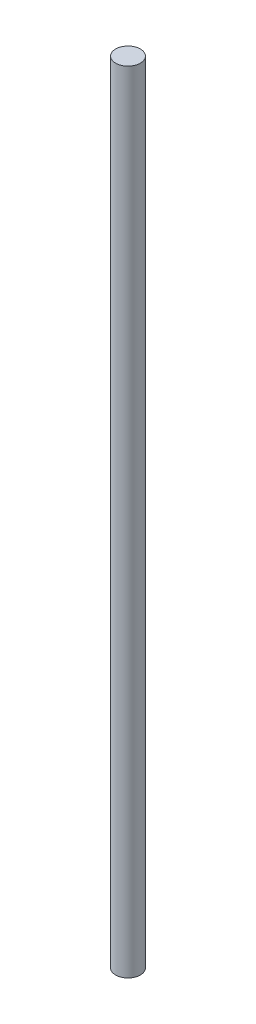
from build123d import *

# Parameters (mm, degrees)
SKETCH1_R           = 3.96875
BOSS_EXTRUDE1_DEPTH = 254


with BuildPart() as part:
    # Sketch1 → Boss-Extrude1 (new body)
    with BuildSketch(Plane(origin=(0, 0, 0), x_dir=(1, 0, 0), z_dir=(0, 1, 0))):
        Circle(SKETCH1_R)
    extrude(amount=BOSS_EXTRUDE1_DEPTH)


solid = part.part
